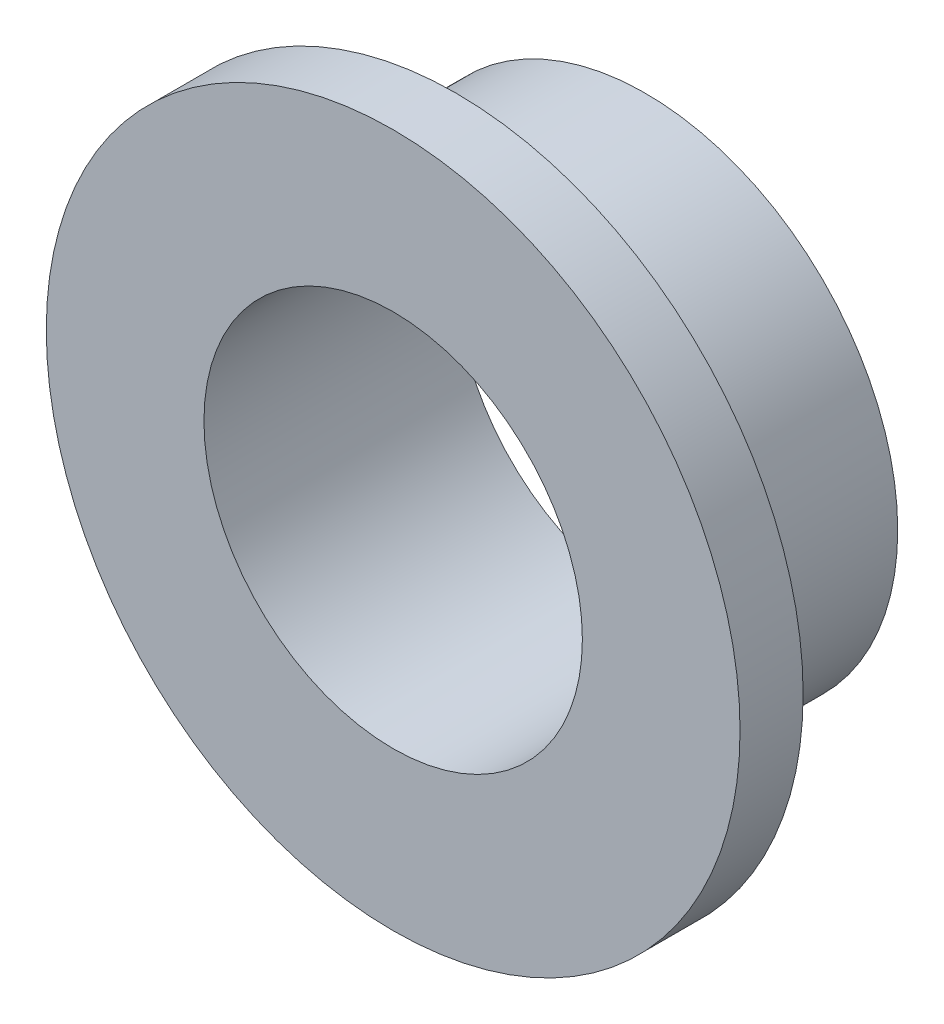
from build123d import *

# Parameters (mm, degrees)
SKETCH1_R           = 6.35
SKETCH1_R_2         = 4.7625
BOSS_EXTRUDE1_DEPTH = 6.35
SKETCH2_R           = 8.73125
SKETCH2_R_2         = 4.7625
BOSS_EXTRUDE2_DEPTH = 1.5875


with BuildPart() as part:
    # Sketch1 → Boss-Extrude1 (new body)
    with BuildSketch(Plane.XY):
        Circle(SKETCH1_R)
        Circle(SKETCH1_R_2, mode=Mode.SUBTRACT)
    extrude(amount=BOSS_EXTRUDE1_DEPTH)

    # Sketch2 → Boss-Extrude2 (add)
    with BuildSketch(Plane.XY.offset(6.35)):
        Circle(SKETCH2_R)
        Circle(SKETCH2_R_2, mode=Mode.SUBTRACT)
    extrude(amount=-BOSS_EXTRUDE2_DEPTH)


solid = part.part
